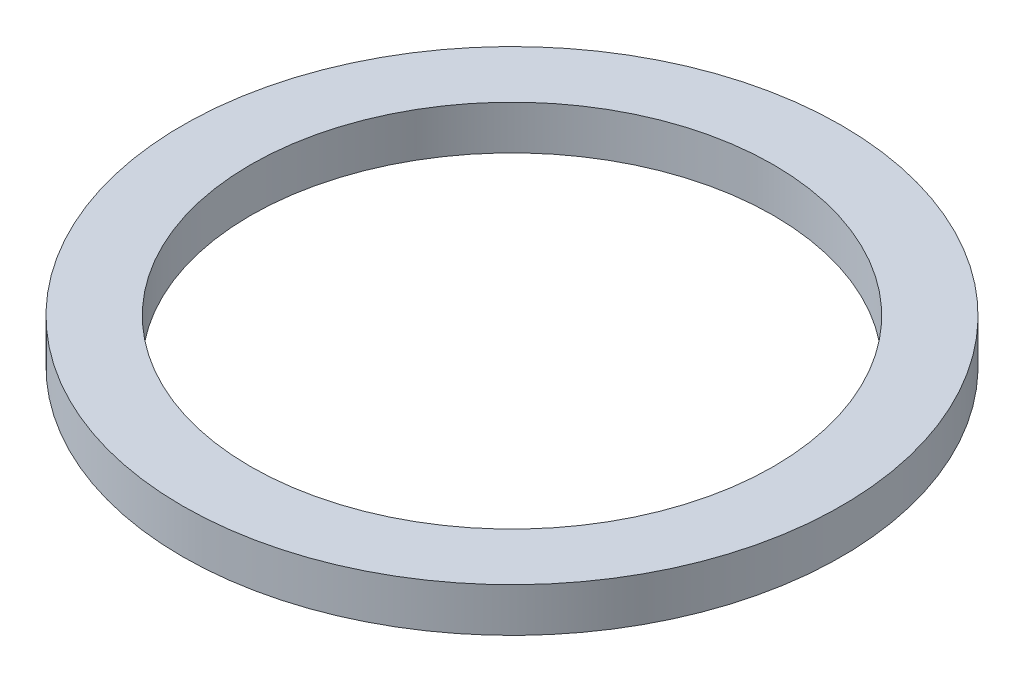
from build123d import *

# Parameters (mm, degrees)
SKETCH2_R           = 7.5
SKETCH2_R_2         = 5.95
BOSS_EXTRUDE1_DEPTH = 1


with BuildPart() as part:
    # Sketch2 → Boss-Extrude1 (new body)
    with BuildSketch(Plane(origin=(0, 0, 0), x_dir=(1, 0, 0), z_dir=(0, 1, 0))):
        Circle(SKETCH2_R)
        Circle(SKETCH2_R_2, mode=Mode.SUBTRACT)
    extrude(amount=BOSS_EXTRUDE1_DEPTH)


solid = part.part
